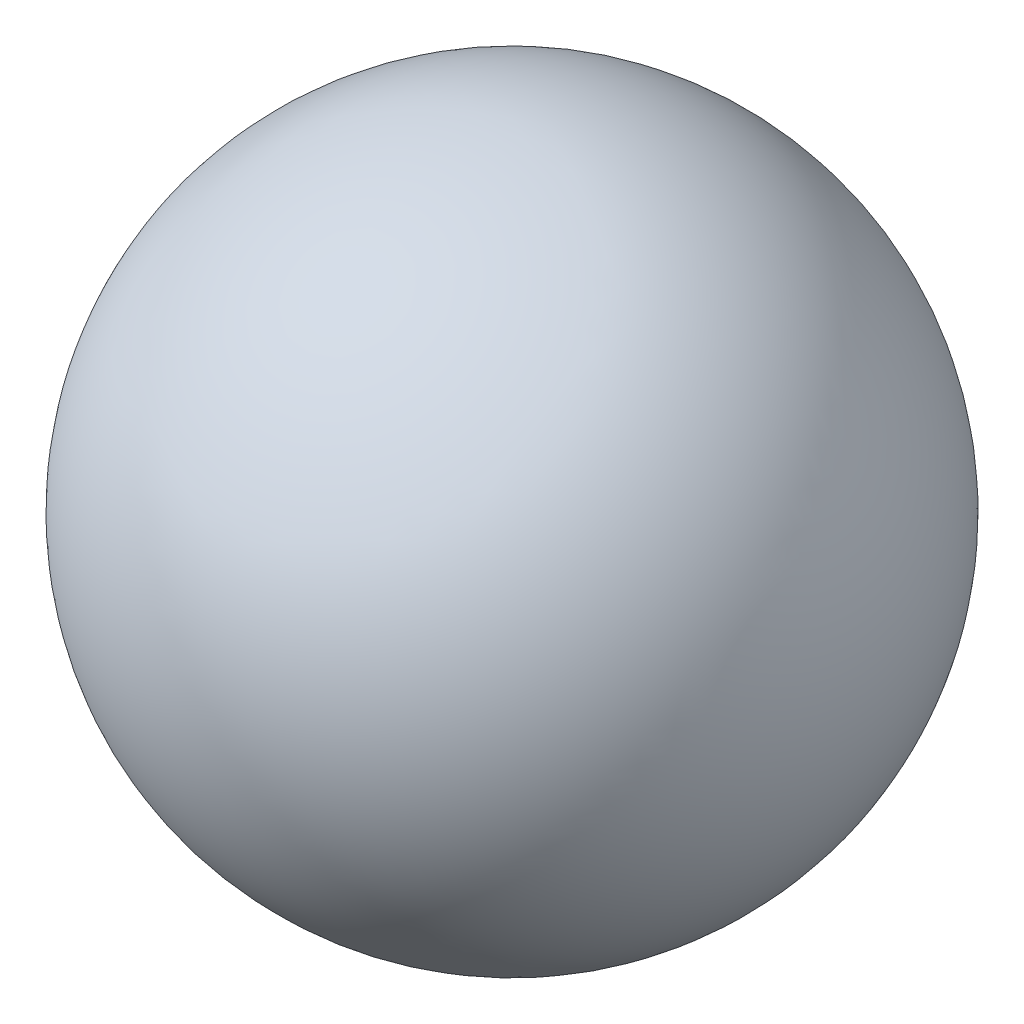
from build123d import *


with BuildPart() as part:
    # Sketch1 → Revolve5 (revolve)
    with BuildSketch(Plane(origin=(0, 0, 0), x_dir=(1, 0, 0), z_dir=(0, 1, 0))):
        with BuildLine():
            Line((-19.939, 0), (19.939, 0))
            ThreePointArc((19.939, 0), (0, 19.939), (-19.939, 0))
        make_face()
    revolve(axis=Axis((-19.939, 0, 0), (1, 0, 0)))


solid = part.part
